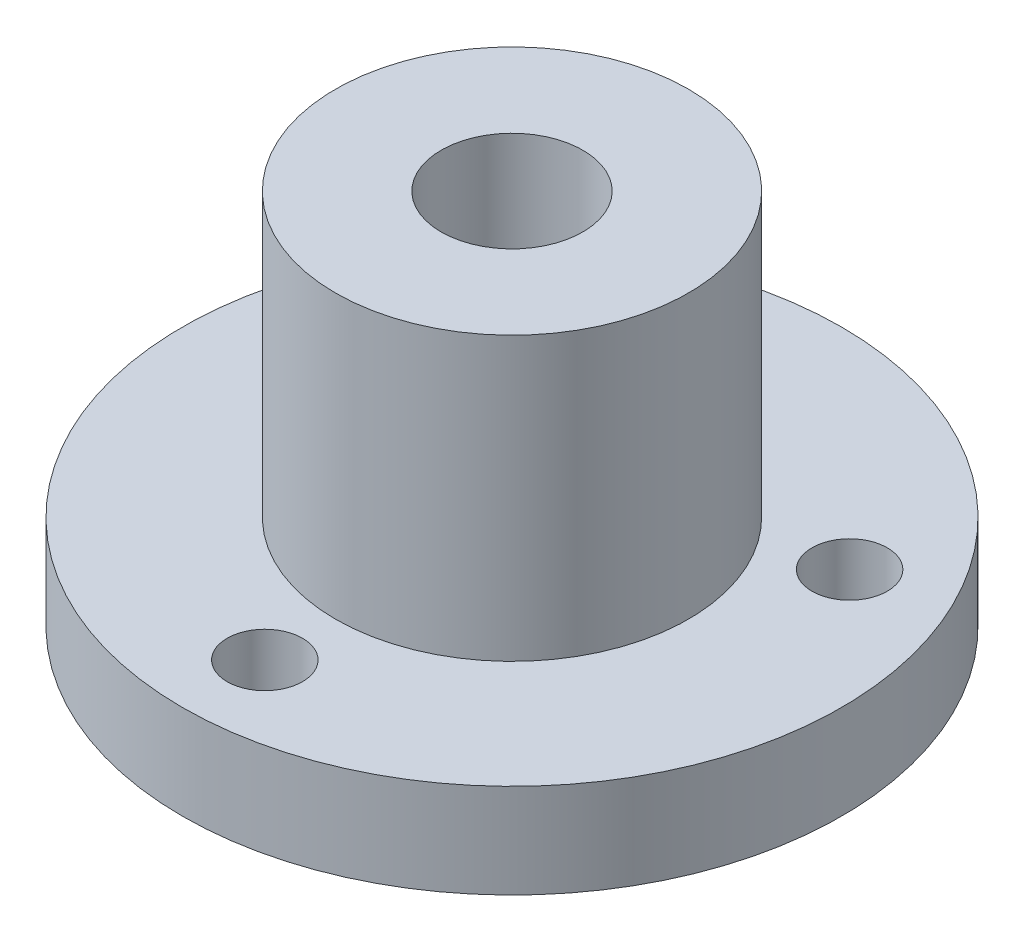
from build123d import *

# Parameters (mm, degrees)
SKETCH2_R           = 14
BOSS_EXTRUDE1_DEPTH = 4
SKETCH3_R           = 7.5
BOSS_EXTRUDE2_DEPTH = 12
SKETCH4_R           = 3.01
CUT_EXTRUDE1_DEPTH  = 17
SKETCH5_R           = 1.6
CUT_EXTRUDE2_DEPTH  = 12


with BuildPart() as part:
    # Sketch2 → Boss-Extrude1 (new body)
    with BuildSketch(Plane(origin=(0, 0, 0), x_dir=(1, 0, 0), z_dir=(0, 1, 0))):
        Circle(SKETCH2_R)
    extrude(amount=BOSS_EXTRUDE1_DEPTH)

    # Sketch3 → Boss-Extrude2 (add)
    with BuildSketch(Plane(origin=(0, 4, 0), x_dir=(1, 0, 0), z_dir=(0, 1, 0))):
        Circle(SKETCH3_R)
    extrude(amount=BOSS_EXTRUDE2_DEPTH)

    # Sketch4 → Cut-Extrude1 (cut, through all)
    with BuildSketch(Plane(origin=(0, 16, 0), x_dir=(1, 0, 0), z_dir=(0, 1, 0))):
        Circle(SKETCH4_R)
    extrude(amount=-CUT_EXTRUDE1_DEPTH, mode=Mode.SUBTRACT)

    # Sketch5 → Cut-Extrude2 (cut)
    with BuildSketch(Plane(origin=(0, 4, 0), x_dir=(1, 0, 0), z_dir=(0, 1, 0))):
        with Locations((0, -10.5)):
            Circle(SKETCH5_R)
        with Locations((9.09326674, 5.25)):
            Circle(SKETCH5_R)
        with Locations((-9.09326674, 5.25)):
            Circle(SKETCH5_R)
    extrude(amount=-CUT_EXTRUDE2_DEPTH, mode=Mode.SUBTRACT)


solid = part.part
